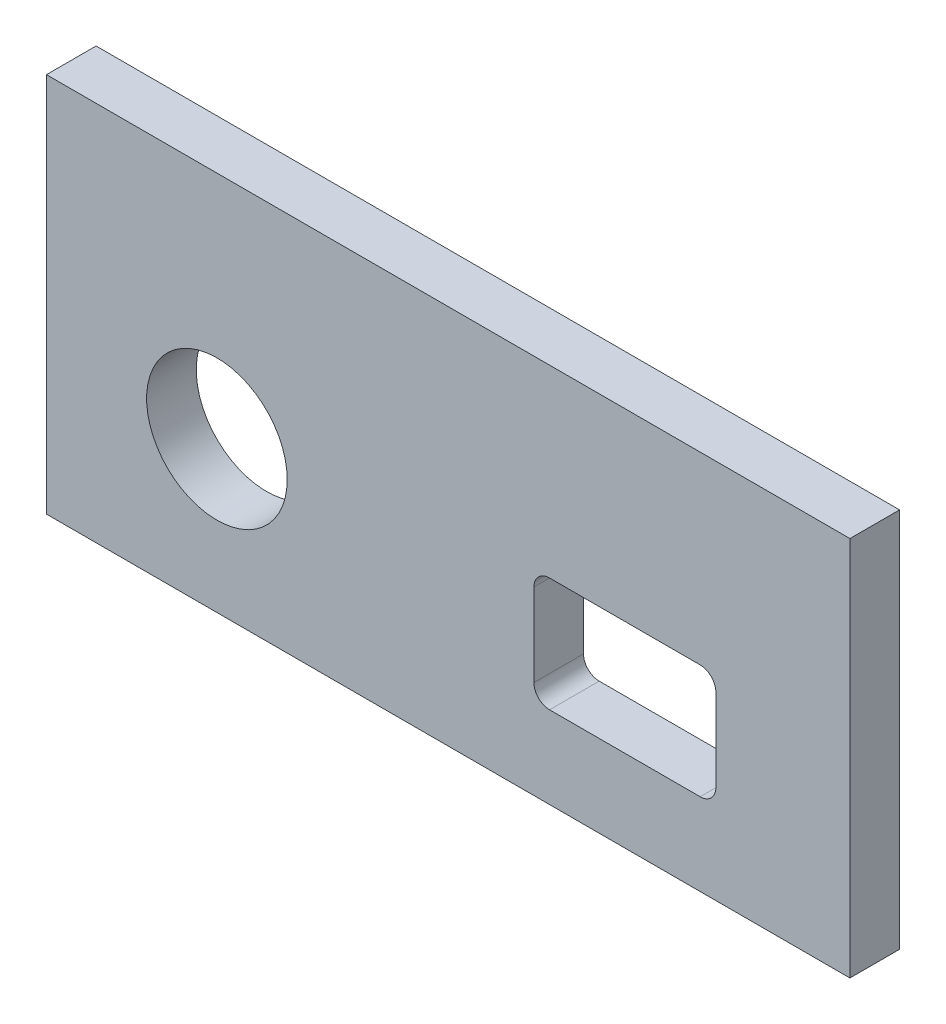
from build123d import *

# Parameters (mm, degrees)
BOSS_EXTRUDE1_START = 0.25
SKETCH1_W           = 48.563793396
SKETCH1_H           = 23.003536126
SKETCH1_R           = 4.25
BOSS_EXTRUDE1_DEPTH = 3


with BuildPart() as part:
    # Sketch1 → Boss-Extrude1 (new body)
    with BuildSketch(Plane.XY.offset(75.780531955).offset(BOSS_EXTRUDE1_START)):
        with Locations((32.639628913, 33.325057501)):
            Rectangle(SKETCH1_W, SKETCH1_H)
        with Locations((18.660828036, 30.906825564)):
            Circle(SKETCH1_R, mode=Mode.SUBTRACT)
        with BuildLine():
            Line((37.818598421, 32.735851952), (37.818598421, 27.735851952))
            ThreePointArc((37.818598421, 27.735851952), (38.096846979, 27.06410051), (38.768598421, 26.785851952))
            Line((38.768598421, 26.785851952), (47.868598421, 26.785851952))
            ThreePointArc((47.868598421, 26.785851952), (48.540349863, 27.06410051), (48.818598421, 27.735851952))
            Line((48.818598421, 27.735851952), (48.818598421, 32.735851952))
            ThreePointArc((48.818598421, 32.735851952), (48.540349863, 33.407603394), (47.868598421, 33.685851952))
            Line((47.868598421, 33.685851952), (38.768598421, 33.685851952))
            ThreePointArc((38.768598421, 33.685851952), (38.096846979, 33.407603394), (37.818598421, 32.735851952))
        make_face(mode=Mode.SUBTRACT)
    extrude(amount=BOSS_EXTRUDE1_DEPTH)


solid = part.part
